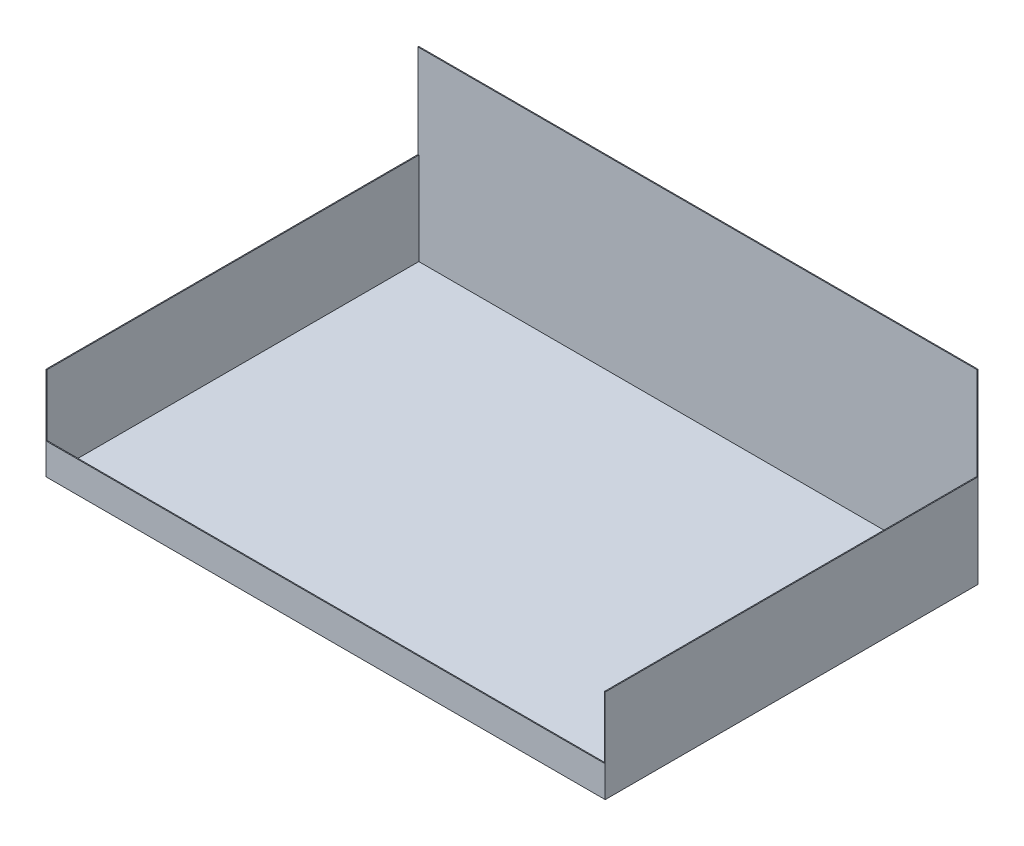
from build123d import *

# Parameters (mm, degrees)
SKETCH2_W               = 900
SKETCH2_H               = 300
BOSS_EXTRUDE1_DEPTH     = 600
CUT_EXTRUDE1_DEPTH      = 1
CUT_EXTRUDE1_DEPTH_BACK = 900
CUT_EXTRUDE2_DEPTH      = 1
CUT_EXTRUDE2_DEPTH_BACK = 598.5
SKETCH6_W               = 897
SKETCH6_H               = 597
CUT_EXTRUDE4_DEPTH      = 48.5


with BuildPart() as part:
    # Sketch2 → Boss-Extrude1 (new body)
    with BuildSketch(Plane.XY):
        with Locations((75.531914894, 52.659574468)):
            Rectangle(SKETCH2_W, SKETCH2_H)
    extrude(amount=-BOSS_EXTRUDE1_DEPTH)

    # Sketch3 → Cut-Extrude1 (cut, two sides)
    with BuildSketch(Plane.ZY.offset(374.468085106)) as cut_extrude1_sk:
        Polygon((-1951.6407865, 202.659574468), (-600, 202.659574468), (-598.5, 202.659574468), (-598.5, 52.659574468), (0, 52.659574468), (1351.6407865, 52.659574468), (1474.268787585, 2753.15834993), (-1829.012785414, 2903.15834993), align=None)
    extrude(amount=CUT_EXTRUDE1_DEPTH, mode=Mode.SUBTRACT)
    extrude(cut_extrude1_sk.sketch, amount=-CUT_EXTRUDE1_DEPTH_BACK, mode=Mode.SUBTRACT)

    # Sketch4 → Cut-Extrude2 (cut, two sides)
    with BuildSketch(Plane.XY) as cut_extrude2_sk:
        Polygon((-2209.296844196, 52.659574468), (-374.468085106, 52.659574468), (-372.968085106, 52.659574468), (-372.968085106, -47.340425532), (524.031914894, -47.340425532), (524.031914894, 52.659574468), (525.531914894, 52.659574468), (2360.360673983, 52.659574468), (2360.360673983, 3722.317092647), (-2209.296844196, 3722.317092647), align=None)
    extrude(amount=CUT_EXTRUDE2_DEPTH, mode=Mode.SUBTRACT)
    extrude(cut_extrude2_sk.sketch, amount=-CUT_EXTRUDE2_DEPTH_BACK, mode=Mode.SUBTRACT)

    # Sketch6 → Cut-Extrude4 (cut)
    with BuildSketch(Plane(origin=(0, -47.340425532, 0), x_dir=(1, 0, 0), z_dir=(0, 1, 0))):
        with Locations((75.531914894, 300)):
            Rectangle(SKETCH6_W, SKETCH6_H)
    extrude(amount=-CUT_EXTRUDE4_DEPTH, mode=Mode.SUBTRACT)


solid = part.part
